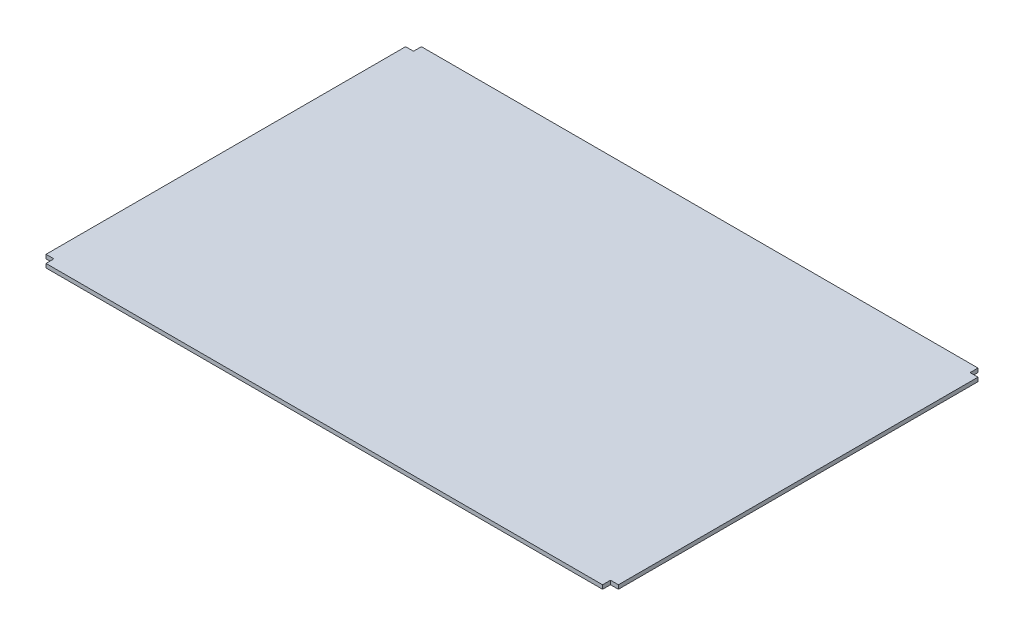
from build123d import *

# Parameters (mm, degrees)
ESTRUSIONE_ESTRUSIONE1_DEPTH = 20


with BuildPart() as part:
    # Schizzo1 → Estrusione-Estrusione1 (new body)
    with BuildSketch(Plane(origin=(0, 0, 0), x_dir=(1, 0, 0), z_dir=(0, 1, 0))):
        Polygon((1388.5, -910), (-1428.5, -910), (-1428.5, -870), (-1468.5, -870), (-1468.5, 950), (-1428.5, 950), (-1428.5, 990), (1388.5, 990), (1388.5, 950), (1428.5, 950), (1428.5, -870), (1388.5, -870), align=None)
    extrude(amount=ESTRUSIONE_ESTRUSIONE1_DEPTH)


solid = part.part
